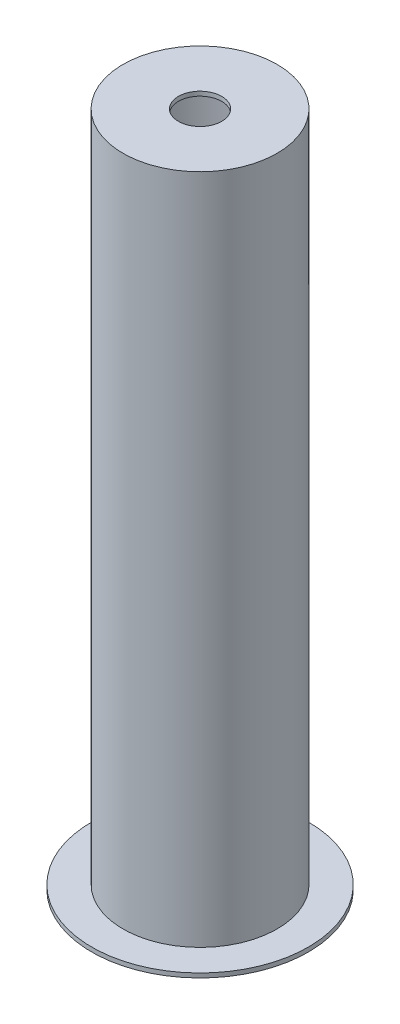
from build123d import *


with BuildPart() as part:
    # Esboço1 → Revolução1 (revolve)
    with BuildSketch(Plane.XY):
        Polygon((50, 1560), (177.8, 1560), (177.8, 10), (250, 10), (250, 0), (170, 0), (170, 10), (173.02, 10), (173.02, 1550), (50, 1550), align=None)
    revolve(axis=Axis((0, 0, 0), (0, 1, 0)))


solid = part.part
